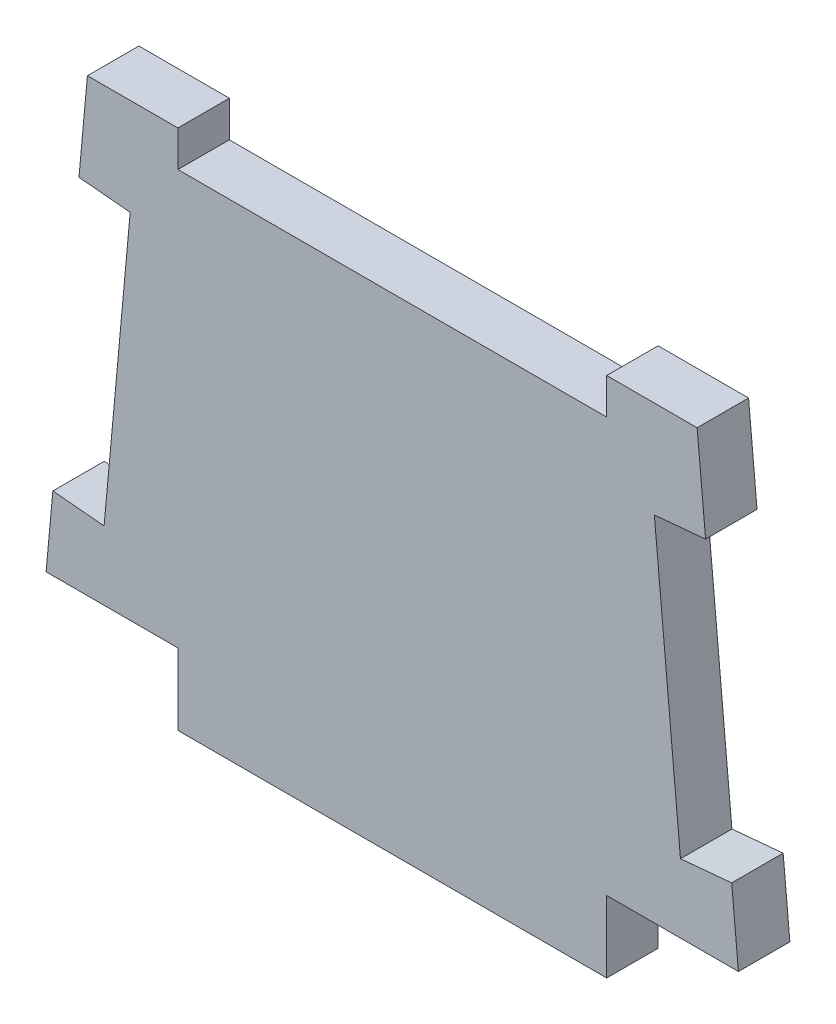
from build123d import *

# Parameters (mm, degrees)
BOSS_EXTRUDE1_DEPTH = 4.572
SKETCH2_W           = 38.1
SKETCH2_H           = 3.2004
CUT_EXTRUDE1_DEPTH  = 5.572
SKETCH3_W           = 38.1
SKETCH3_H           = 6.35
BOSS_EXTRUDE2_DEPTH = 4.572


with BuildPart() as part:
    # Sketch1 → Boss-Extrude1 (new body)
    with BuildSketch(Plane.XY):
        Polygon((-27.0891, 18.738007515), (27.0891, 18.738007515), (30.7594, -21.276818659), (-30.7594, -21.276818659), align=None)
    extrude(amount=BOSS_EXTRUDE1_DEPTH)

    # Sketch2 → Cut-Extrude1 (cut, through all)
    with BuildSketch(Plane.XY.offset(4.572)):
        with Locations((0, 17.137807515)):
            Rectangle(SKETCH2_W, SKETCH2_H)
        Polygon((-30.160830215, -14.751012621), (-27.840792288, 10.542809234), (-23.287904354, 10.125202407), (-25.607942281, -15.168619448), align=None)
        Polygon((27.840792288, 10.542809234), (30.160830215, -14.751012621), (25.607942281, -15.168619448), (23.287904354, 10.125202407), align=None)
    extrude(amount=-CUT_EXTRUDE1_DEPTH, mode=Mode.SUBTRACT)

    # Sketch3 → Boss-Extrude2 (add)
    with BuildSketch(Plane.XY.offset(4.572)):
        with Locations((0, -24.451818659)):
            Rectangle(SKETCH3_W, SKETCH3_H)
    extrude(amount=-BOSS_EXTRUDE2_DEPTH)


solid = part.part
